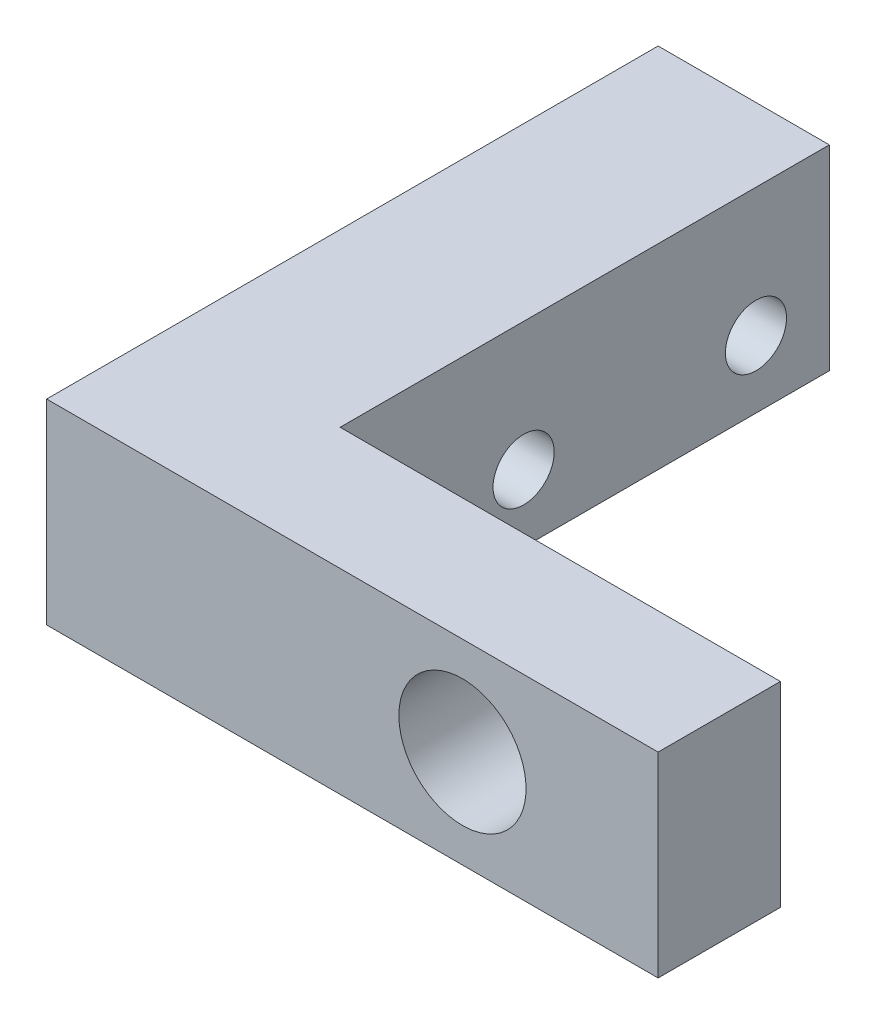
from build123d import *

# Parameters (mm, degrees)
BOSS_EXTRUDE1_DEPTH = 8
CUT_EXTRUDE1_REACH  = 27
SKETCH2_R           = 1.25
CUT_EXTRUDE2_REACH  = 7
SKETCH4_R           = 2.6


with BuildPart() as part:
    # Sketch1 → Boss-Extrude1 (new body)
    with BuildSketch(Plane(origin=(0, 0, 0), x_dir=(1, 0, 0), z_dir=(0, 1, 0))):
        Polygon((0, 0), (0, 25), (7, 25), (7, 5), (25, 5), (25, 0), align=None)
    extrude(amount=BOSS_EXTRUDE1_DEPTH)

    # Sketch2 → Cut-Extrude1 (cut, up to next)
    with BuildSketch(Plane.ZY, mode=Mode.PRIVATE) as cut_extrude1_sk1:
        with Locations((-22, 2.75)):
            Circle(SKETCH2_R)
    cut_extrude1_tool1 = extrude(cut_extrude1_sk1.sketch, amount=-CUT_EXTRUDE1_REACH, mode=Mode.PRIVATE) & part.part
    add(cut_extrude1_tool1.solids().sort_by_distance((0, 2.75, -22))[0], mode=Mode.SUBTRACT)
    # Sketch2 → Cut-Extrude1 (cut, up to next)
    with BuildSketch(Plane.ZY, mode=Mode.PRIVATE) as cut_extrude1_sk2:
        with Locations((-12.5, 2.75)):
            Circle(SKETCH2_R)
    cut_extrude1_tool2 = extrude(cut_extrude1_sk2.sketch, amount=-CUT_EXTRUDE1_REACH, mode=Mode.PRIVATE) & part.part
    add(cut_extrude1_tool2.solids().sort_by_distance((0, 2.75, -12.5))[0], mode=Mode.SUBTRACT)

    # Sketch4 → Cut-Extrude2 (cut, up to next)
    with BuildSketch(Plane(origin=(0, 0, -5), x_dir=(-1, 0, 0), z_dir=(0, 0, -1)), mode=Mode.PRIVATE) as cut_extrude2_sk1:
        with Locations((-17, 4)):
            Circle(SKETCH4_R)
    cut_extrude2_tool1 = extrude(cut_extrude2_sk1.sketch, amount=-CUT_EXTRUDE2_REACH, mode=Mode.PRIVATE) & part.part
    add(cut_extrude2_tool1.solids().sort_by_distance((17, 4, -5))[0], mode=Mode.SUBTRACT)


solid = part.part
